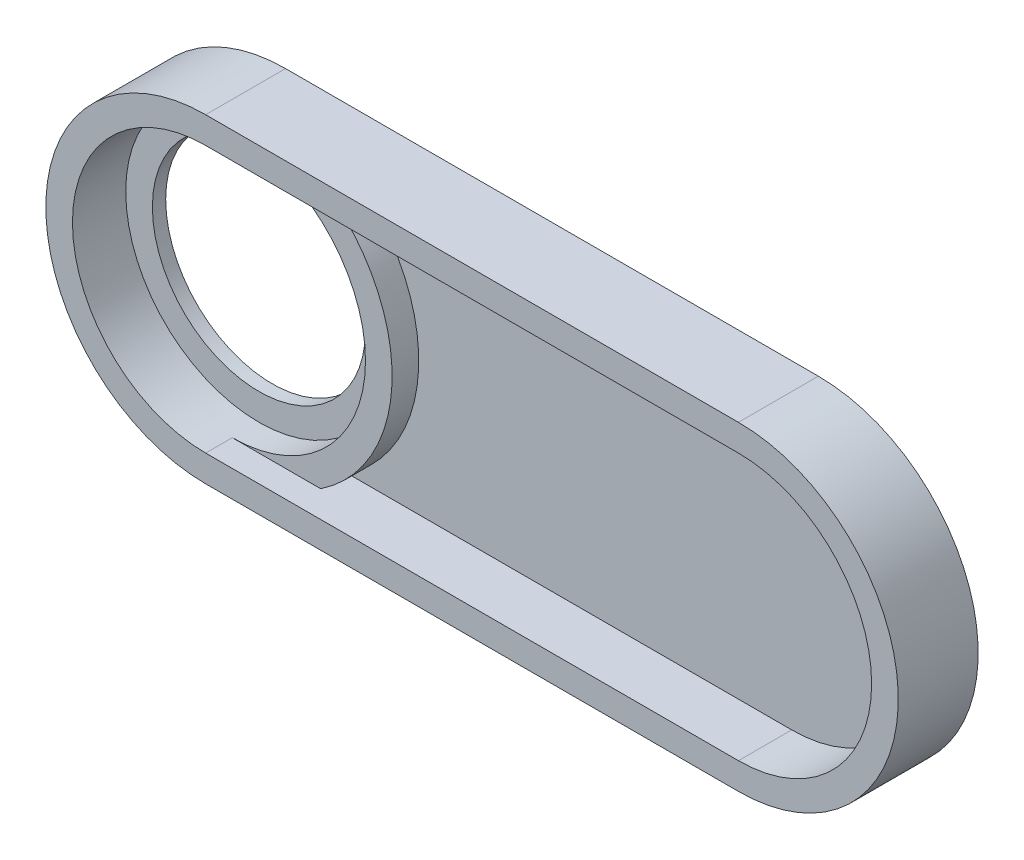
from build123d import *

# Parameters (mm, degrees)
SKETCH1_R           = 40
BOSS_EXTRUDE1_DEPTH = 10
SKETCH2_R           = 52.5
CUT_EXTRUDE1_DEPTH  = 5
SKETCH3_R           = 50
BOSS_EXTRUDE2_DEPTH = 10
BOSS_EXTRUDE3_DEPTH = 20


with BuildPart() as part:
    # Sketch1 → Boss-Extrude1 (new body)
    with BuildSketch(Plane.XY):
        with BuildLine():
            Line((0, 60), (200, 60))
            ThreePointArc((200, 60), (260, 0), (200, -60))
            Line((200, -60), (0, -60))
            ThreePointArc((0, -60), (-60, 0), (0, 60))
        make_face()
        Circle(SKETCH1_R, mode=Mode.SUBTRACT)
    extrude(amount=BOSS_EXTRUDE1_DEPTH)

    # Sketch2 → Cut-Extrude1 (cut)
    with BuildSketch(Plane(origin=(0, 0, 0), x_dir=(-1, 0, 0), z_dir=(0, 0, -1))):
        Circle(SKETCH2_R)
    extrude(amount=-CUT_EXTRUDE1_DEPTH, mode=Mode.SUBTRACT)

    # Sketch3 → Boss-Extrude2 (add)
    with BuildSketch(Plane.XY.offset(10)):
        with BuildLine():
            ThreePointArc((0, -60), (42.426406871, -42.426406871), (60, 0))
            ThreePointArc((60, 0), (42.426406871, 42.426406871), (0, 60))
            ThreePointArc((0, 60), (-60, 0), (0, -60))
        make_face()
        Circle(SKETCH3_R, mode=Mode.SUBTRACT)
    extrude(amount=BOSS_EXTRUDE2_DEPTH)

    # Sketch4 → Boss-Extrude3 (add)
    with BuildSketch(Plane.XY.offset(10)):
        with BuildLine():
            Line((0, -60), (200, -60))
            ThreePointArc((200, -60), (260, 0), (200, 60))
            Line((200, 60), (0, 60))
            ThreePointArc((0, 60), (-60, 0), (0, -60))
        make_face()
        with BuildLine():
            Line((200, 50), (0, 50))
            ThreePointArc((0, 50), (-50, 0), (0, -50))
            Line((0, -50), (200, -50))
            ThreePointArc((200, -50), (250, 0), (200, 50))
        make_face(mode=Mode.SUBTRACT)
    extrude(amount=BOSS_EXTRUDE3_DEPTH)


solid = part.part
